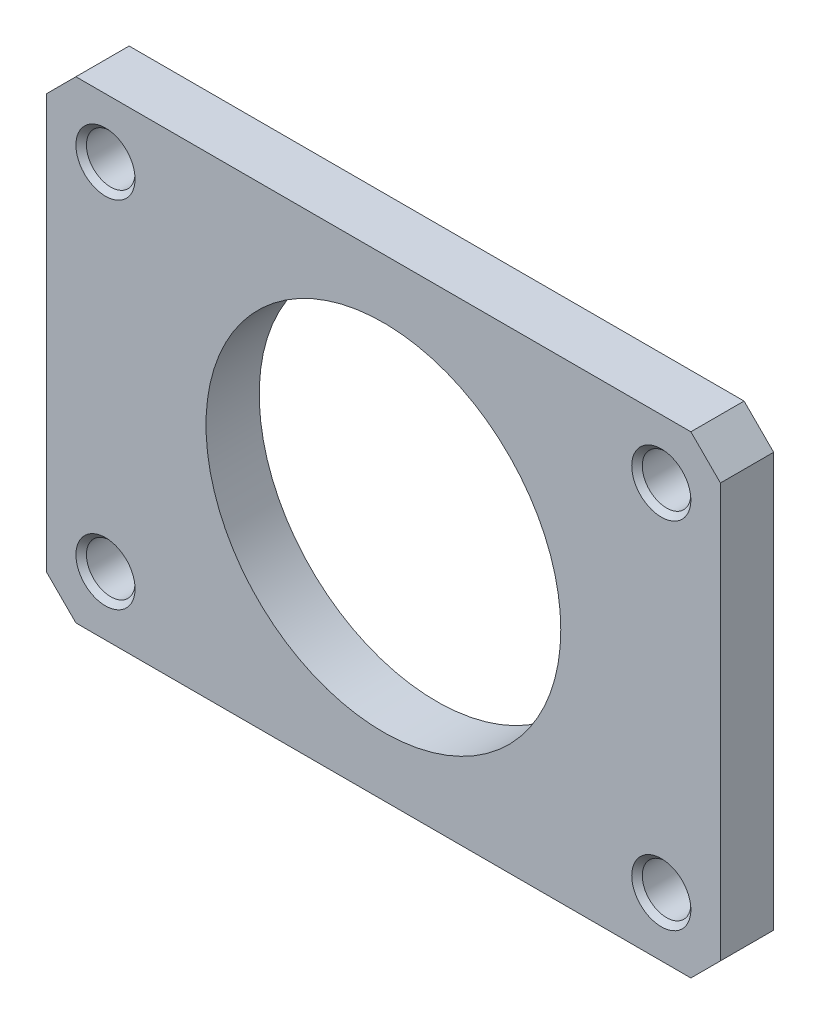
from build123d import *

# Parameters (mm, degrees)
SKETCH_1_W          = 28.5
SKETCH_1_H          = 20
SKETCH_1_R          = 2.055
EXTRUDE_1_DEPTH     = 4.5
CHAMFER_1_SIZE      = 2.5
CHAMFER_2_SIZE      = 0.445
SKETCH_2_R          = 15
CUT_EXTRUDE_1_DEPTH = 5.5


with BuildPart() as part:
    # Эскиз1 → Бобышка-Вытянуть1 (new body)
    with BuildSketch(Plane.XY):
        Rectangle(SKETCH_1_W, SKETCH_1_H)
        with Locations((9.25, 5)):
            Circle(SKETCH_1_R, mode=Mode.SUBTRACT)
    extrude(amount=EXTRUDE_1_DEPTH)

    # Фаска1
    chamfer_1_edges = [part.edges().sort_by_distance(p)[0] for p in [
        (14.25, 10, 2.25),
    ]]
    chamfer(chamfer_1_edges, length=CHAMFER_1_SIZE)

    # Фаска2
    chamfer_2_edges = [part.edges().sort_by_distance(p)[0] for p in [
        (7.195, 5, 0),
        (7.195, 5, 4.5),
    ]]
    chamfer(chamfer_2_edges, length=CHAMFER_2_SIZE)

    # Зеркальное отражение1: part across plane


with BuildPart() as part_1:
    add(part.part)
    add(part.part.mirror(Plane(origin=(-14.25, -10, 4.5), x_dir=(0, 0, 1), z_dir=(0, 1, 0))))

    # Зеркальное отражение2: part across plane


with BuildPart() as part_2:
    add(part_1.part)
    add(part_1.part.mirror(Plane(origin=(-14.25, -10, 4.5), x_dir=(0, 0, 1), z_dir=(1, 0, 0))))

    # Эскиз2 → Вырез-Вытянуть1 (cut, through all)
    with BuildSketch(Plane.XY.offset(4.5)):
        with Locations((-14.25, -10)):
            Circle(SKETCH_2_R)
    extrude(amount=-CUT_EXTRUDE_1_DEPTH, mode=Mode.SUBTRACT)


solid = part_2.part
